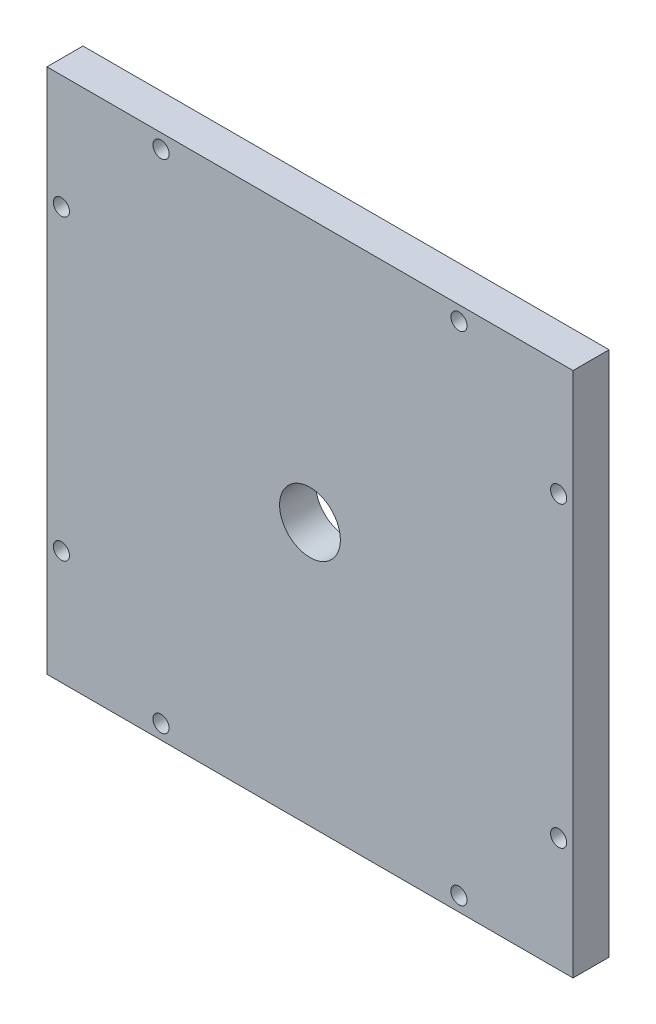
from build123d import *

# Parameters (mm, degrees)
SKETCH1_W           = 92.71
SKETCH1_H           = 92.71
SKETCH1_R           = 5.3578125
BOSS_EXTRUDE1_DEPTH = 6.35
SKETCH2_R           = 1.4224
CUT_EXTRUDE1_DEPTH  = 6.35


with BuildPart() as part:
    # Sketch1 → Boss-Extrude1 (new body)
    with BuildSketch(Plane.XY):
        with Locations((46.355, 46.355)):
            Rectangle(SKETCH1_W, SKETCH1_H)
        with Locations((46.355, 46.355)):
            Circle(SKETCH1_R, mode=Mode.SUBTRACT)
    extrude(amount=BOSS_EXTRUDE1_DEPTH)

    # Sketch2 → Cut-Extrude1 (cut)
    with BuildSketch(Plane.XY.offset(6.35)):
        with Locations((2.54, 20.100036)):
            Circle(SKETCH2_R)
        with Locations((20.100036, 2.54)):
            Circle(SKETCH2_R)
        with Locations((72.609964, 2.54)):
            Circle(SKETCH2_R)
        with Locations((90.17, 20.100036)):
            Circle(SKETCH2_R)
        with Locations((90.17, 72.609964)):
            Circle(SKETCH2_R)
        with Locations((72.609964, 90.17)):
            Circle(SKETCH2_R)
        with Locations((20.100036, 90.17)):
            Circle(SKETCH2_R)
        with Locations((2.54, 72.609964)):
            Circle(SKETCH2_R)
    extrude(amount=-CUT_EXTRUDE1_DEPTH, mode=Mode.SUBTRACT)


solid = part.part
